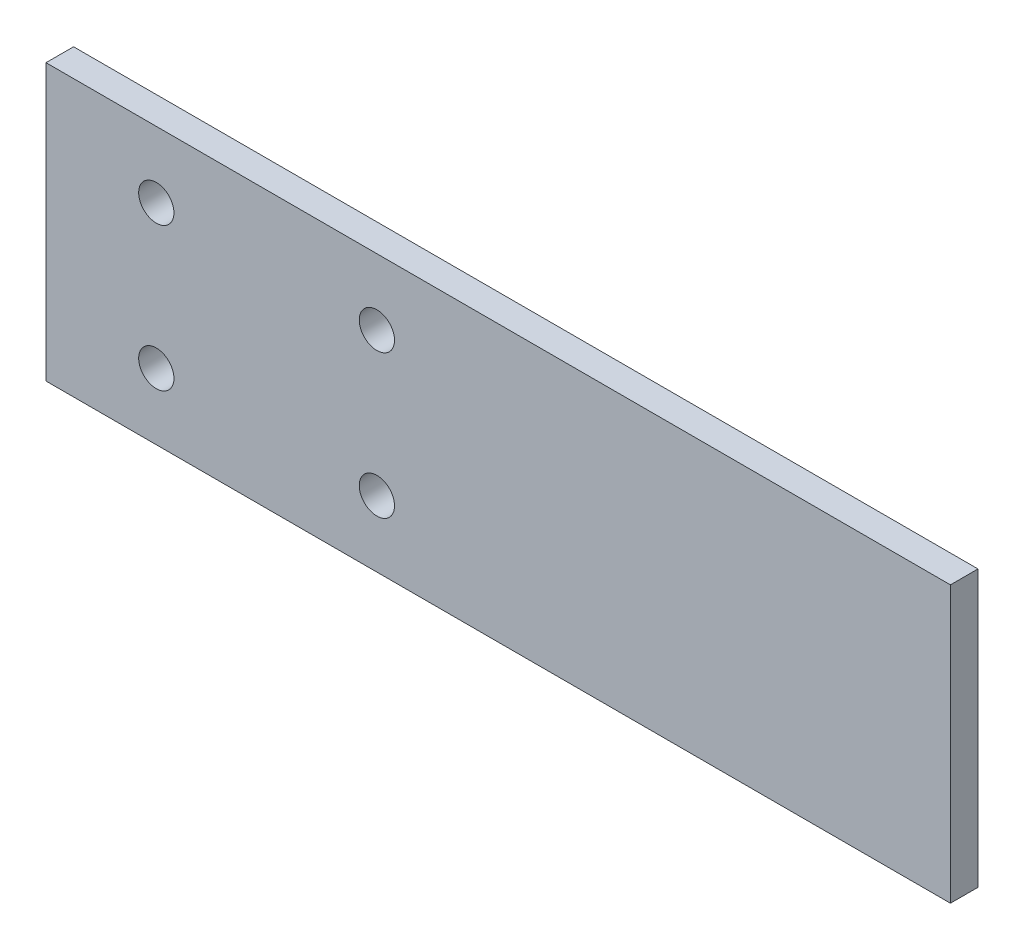
from build123d import *

# Parameters (mm, degrees)
SKETCH1_W           = 82
SKETCH1_H           = 25
SKETCH1_R           = 1.6
BOSS_EXTRUDE1_DEPTH = 2.5


with BuildPart() as part:
    # Sketch1 → Boss-Extrude1 (new body)
    with BuildSketch(Plane.XY):
        with Locations((24.84, -3.58)):
            Rectangle(SKETCH1_W, SKETCH1_H)
        with Locations((-6.16, 2.92)):
            Circle(SKETCH1_R, mode=Mode.SUBTRACT)
        with Locations((-6.16, -10.08)):
            Circle(SKETCH1_R, mode=Mode.SUBTRACT)
        with Locations((13.84, 2.92)):
            Circle(SKETCH1_R, mode=Mode.SUBTRACT)
        with Locations((13.84, -10.08)):
            Circle(SKETCH1_R, mode=Mode.SUBTRACT)
    extrude(amount=BOSS_EXTRUDE1_DEPTH)


solid = part.part
